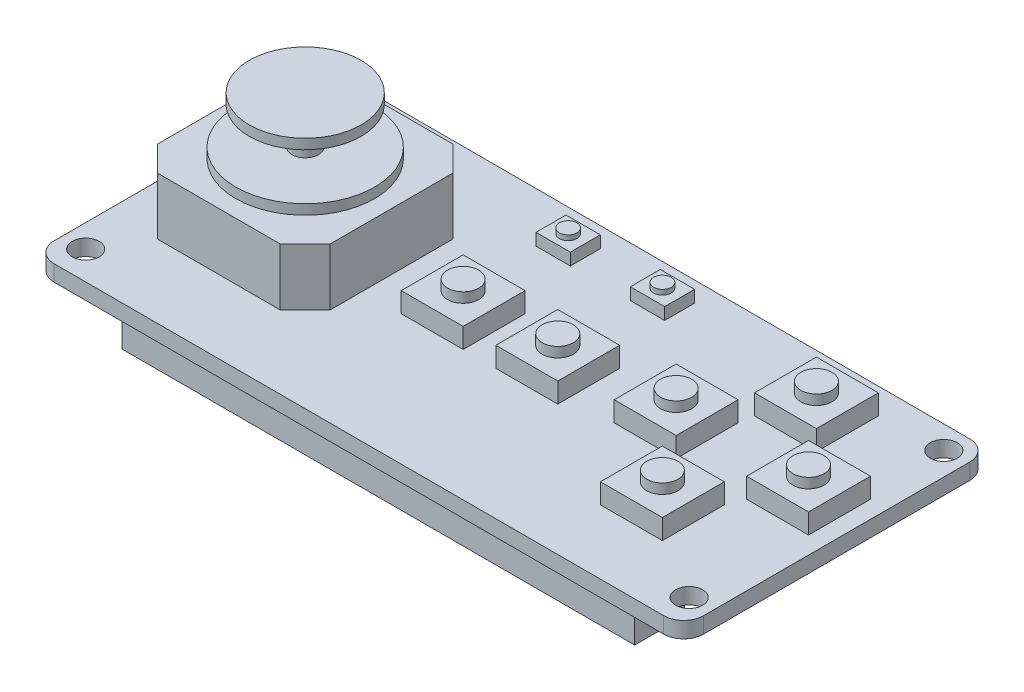
from build123d import *

# Parameters (mm, degrees)
SKETCH_1_W          = 65
SKETCH_1_H          = 30.64
EXTRUDE_1_DEPTH     = 1.6
FILLET_1_R          = 2
SKETCH_2_R          = 1.35
CUT_EXTRUDE_1_DEPTH = 1.6
SKETCH_3_W          = 51.3
SKETCH_3_H          = 5
EXTRUDE_2_DEPTH     = 4
SKETCH_4_W          = 17.3
SKETCH_4_H          = 17.3
EXTRUDE_3_DEPTH     = 5.72
CHAMFER_1_SIZE      = 2.5
SKETCH_5_R          = 6.95
EXTRUDE_4_DEPTH     = 1
SKETCH_6_R          = 1.326147724
EXTRUDE_5_DEPTH     = 3.72
SKETCH_7_R          = 5.6
EXTRUDE_6_DEPTH     = 1
SKETCH_8_W          = 6.2
SKETCH_8_H          = 6.2
EXTRUDE_7_DEPTH     = 2
SKETCH_9_R          = 1.56
EXTRUDE_8_DEPTH     = 1
SKETCH_10_W         = 3.44
SKETCH_10_H         = 3
EXTRUDE_9_DEPTH     = 1.2
SKETCH_11_R         = 0.875
EXTRUDE_10_DEPTH    = 0.5


with BuildPart() as part:
    # 草图1 → 凸台-拉伸1 (new body)
    with BuildSketch(Plane(origin=(0, 0, 0), x_dir=(1, 0, 0), z_dir=(0, 1, 0))):
        with Locations((-2.796247961, 2.767463295)):
            Rectangle(SKETCH_1_W, SKETCH_1_H)
    extrude(amount=EXTRUDE_1_DEPTH)

    # 圆角1
    fillet_1_edges = [part.edges().sort_by_distance(p)[0] for p in [
        (-35.296247961, 0.8, -18.087463295),
        (29.703752039, 0.8, -18.087463295),
        (29.703752039, 0.8, 12.552536705),
        (-35.296247961, 0.8, 12.552536705),
    ]]
    fillet(fillet_1_edges, radius=FILLET_1_R)

    # 草图2 → 切除-拉伸1 (cut)
    with BuildSketch(Plane(origin=(0, 1.6, 0), x_dir=(1, 0, 0), z_dir=(0, 1, 0))):
        with Locations(Location((-32.996247961, 15.787463295, 0), (0, 0, 270))):  # turned: the seam where the file's is
            Circle(SKETCH_2_R)
        with Locations(Location((27.403752039, 15.787463295, 0), (0, 0, 270))):  # turned: the seam where the file's is
            Circle(SKETCH_2_R)
        with Locations(Location((27.403752039, -9.702536705, 0), (0, 0, 270))):  # turned: the seam where the file's is
            Circle(SKETCH_2_R)
        with Locations(Location((-32.996247961, -9.702536705, 0), (0, 0, 270))):  # turned: the seam where the file's is
            Circle(SKETCH_2_R)
    extrude(amount=-CUT_EXTRUDE_1_DEPTH, mode=Mode.SUBTRACT)

    # 草图3 → 凸台-拉伸2 (add)
    with BuildSketch(Plane.XZ):
        with Locations((-2.446247961, 8.452536705)):
            Rectangle(SKETCH_3_W, SKETCH_3_H)
    extrude(amount=EXTRUDE_2_DEPTH)

    # 草图4 → 凸台-拉伸3 (add)
    with BuildSketch(Plane(origin=(0, 1.6, 0), x_dir=(1, 0, 0), z_dir=(0, 1, 0))):
        with Locations((-24.136247961, 3.407463295)):
            Rectangle(SKETCH_4_W, SKETCH_4_H)
    extrude(amount=EXTRUDE_3_DEPTH)

    # 倒角1
    chamfer_1_edges = [part.edges().sort_by_distance(p)[0] for p in [
        (-32.786247961, 4.46, -12.057463295),
        (-32.786247961, 4.46, 5.242536705),
        (-15.486247961, 4.46, 5.242536705),
        (-15.486247961, 4.46, -12.057463295),
    ]]
    chamfer(chamfer_1_edges, length=CHAMFER_1_SIZE)

    # 草图5 → 凸台-拉伸4 (add)
    with BuildSketch(Plane(origin=(0, 7.32, 0), x_dir=(1, 0, 0), z_dir=(0, 1, 0))):
        with Locations(Location((-24.136247961, 3.407463295, 0), (0, 0, 270))):  # turned: the seam where the file's is
            Circle(SKETCH_5_R)
    extrude(amount=EXTRUDE_4_DEPTH)

    # 草图6 → 凸台-拉伸5 (add)
    with BuildSketch(Plane(origin=(0, 8.32, 0), x_dir=(1, 0, 0), z_dir=(0, 1, 0))):
        with Locations(Location((-24.136247961, 3.407463295, 0), (0, 0, 270))):  # turned: the seam where the file's is
            Circle(SKETCH_6_R)
    extrude(amount=EXTRUDE_5_DEPTH)

    # 草图7 → 凸台-拉伸6 (add)
    with BuildSketch(Plane(origin=(0, 12.04, 0), x_dir=(1, 0, 0), z_dir=(0, 1, 0))):
        with Locations(Location((-24.136247961, 3.407463295, 0), (0, 0, 270))):  # turned: the seam where the file's is
            Circle(SKETCH_7_R)
    extrude(amount=EXTRUDE_6_DEPTH)

    # 草图8 → 凸台-拉伸7 (add)
    with BuildSketch(Plane(origin=(0, 1.6, 0), x_dir=(1, 0, 0), z_dir=(0, 1, 0))):
        with Locations((-8.506247961, 3.587463295)):
            Rectangle(SKETCH_8_W, SKETCH_8_H)
        with Locations((0.963752039, 3.587463295)):
            Rectangle(SKETCH_8_W, SKETCH_8_H)
        with Locations((11.613752039, 4.787463295)):
            Rectangle(SKETCH_8_W, SKETCH_8_H)
        with Locations((18.033752039, 12.407463295)):
            Rectangle(SKETCH_8_W, SKETCH_8_H)
        with Locations((24.863752039, 4.787463295)):
            Rectangle(SKETCH_8_W, SKETCH_8_H)
        with Locations((18.033752039, -3.012536705)):
            Rectangle(SKETCH_8_W, SKETCH_8_H)
    extrude(amount=EXTRUDE_7_DEPTH)

    # 草图9 → 凸台-拉伸8 (add)
    with BuildSketch(Plane(origin=(0, 3.6, 0), x_dir=(1, 0, 0), z_dir=(0, 1, 0))):
        with Locations(Location((-8.506247961, 3.587463295, 0), (0, 0, 270))):  # turned: the seam where the file's is
            Circle(SKETCH_9_R)
        with Locations(Location((0.963752039, 3.587463295, 0), (0, 0, 270))):  # turned: the seam where the file's is
            Circle(SKETCH_9_R)
        with Locations(Location((11.613752039, 4.787463295, 0), (0, 0, 270))):  # turned: the seam where the file's is
            Circle(SKETCH_9_R)
        with Locations(Location((18.033752039, 12.407463295, 0), (0, 0, 270))):  # turned: the seam where the file's is
            Circle(SKETCH_9_R)
        with Locations(Location((24.863752039, 4.787463295, 0), (0, 0, 270))):  # turned: the seam where the file's is
            Circle(SKETCH_9_R)
        with Locations(Location((18.033752039, -3.012536705, 0), (0, 0, 270))):  # turned: the seam where the file's is
            Circle(SKETCH_9_R)
    extrude(amount=EXTRUDE_8_DEPTH)

    # 草图10 → 凸台-拉伸9 (add)
    with BuildSketch(Plane(origin=(0, 1.6, 0), x_dir=(1, 0, 0), z_dir=(0, 1, 0))):
        with Locations((-8.996247961, 14.587463295)):
            Rectangle(SKETCH_10_W, SKETCH_10_H)
        with Locations((0.443752039, 14.587463295)):
            Rectangle(SKETCH_10_W, SKETCH_10_H)
    extrude(amount=EXTRUDE_9_DEPTH)

    # 草图11 → 凸台-拉伸10 (add)
    with BuildSketch(Plane(origin=(0, 2.8, 0), x_dir=(1, 0, 0), z_dir=(0, 1, 0))):
        with Locations(Location((-8.996247961, 14.587463295, 0), (0, 0, 270))):  # turned: the seam where the file's is
            Circle(SKETCH_11_R)
        with Locations(Location((0.443752039, 14.587463295, 0), (0, 0, 270))):  # turned: the seam where the file's is
            Circle(SKETCH_11_R)
    extrude(amount=EXTRUDE_10_DEPTH)


solid = part.part
